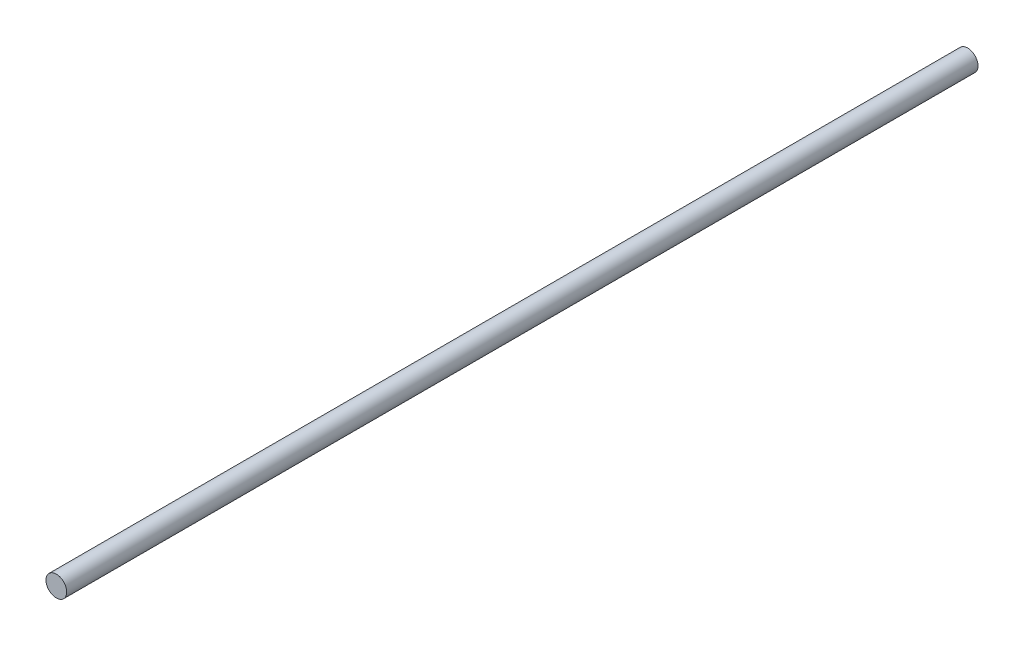
from build123d import *

# Parameters (mm, degrees)
SKETCH1_R           = 3.175
BOSS_EXTRUDE1_DEPTH = 279.4


with BuildPart() as part:
    # Sketch1 → Boss-Extrude1 (new body)
    with BuildSketch(Plane.XY):
        Circle(SKETCH1_R)
    extrude(amount=BOSS_EXTRUDE1_DEPTH)


solid = part.part
